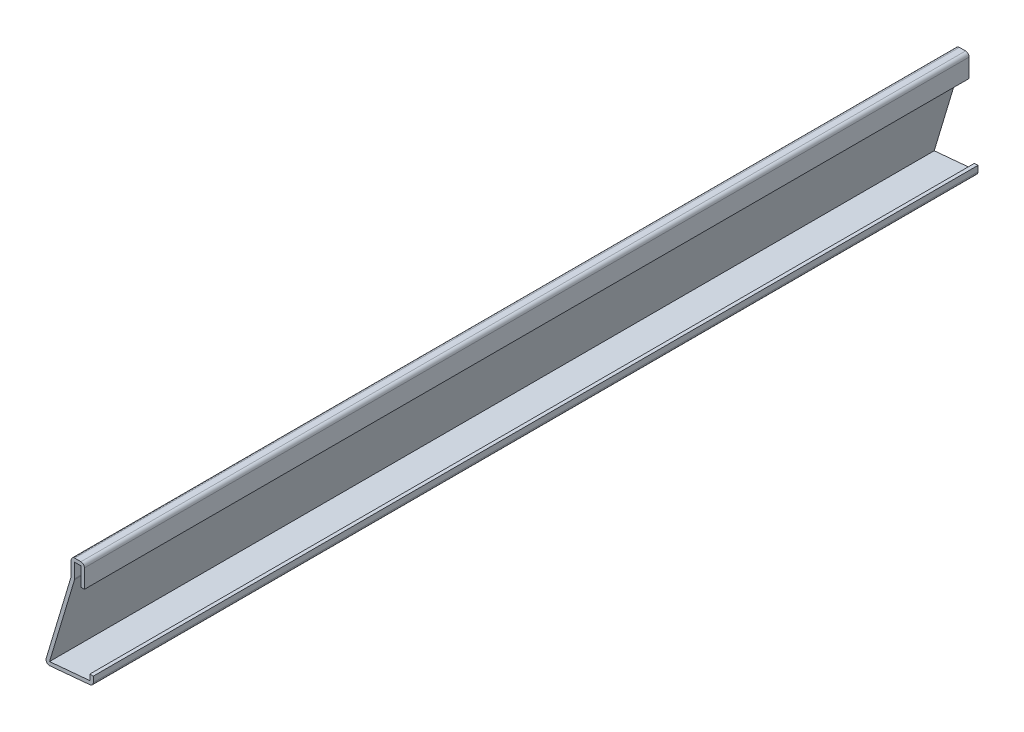
from build123d import *

# Parameters (mm, degrees)
EXTRUDE_THIN1_DEPTH = 317.5
FILLET1_R           = 1.27


with BuildPart() as part:
    # Sketch1 → Extrude-Thin1 (new body)
    with BuildSketch(Plane.XY):
        Polygon((0, 4.7625), (0, 1.5875), (-17.4625, 0), (-7.9375, 31.75), (-7.9375, 38.1), (-3.175, 38.1), (-3.175, 30.1625), (-4.445, 30.1625), (-4.445, 36.83), (-6.6675, 36.83), (-6.6675, 31.563603578), (-15.706108342, 1.434909105), (-1.27, 2.74728259), (-1.27, 4.7625), align=None)
    extrude(amount=-EXTRUDE_THIN1_DEPTH)

    # Fillet1
    fillet1_edges = [part.edges().sort_by_distance(p)[0] for p in [
        (-6.6675, 31.563603578, -158.75),
        (0, 1.5875, -158.75),
        (-17.4625, 0, -158.75),
        (-7.9375, 38.1, -158.75),
        (-3.175, 38.1, -158.75),
    ]]
    fillet(fillet1_edges, radius=FILLET1_R)


solid = part.part
